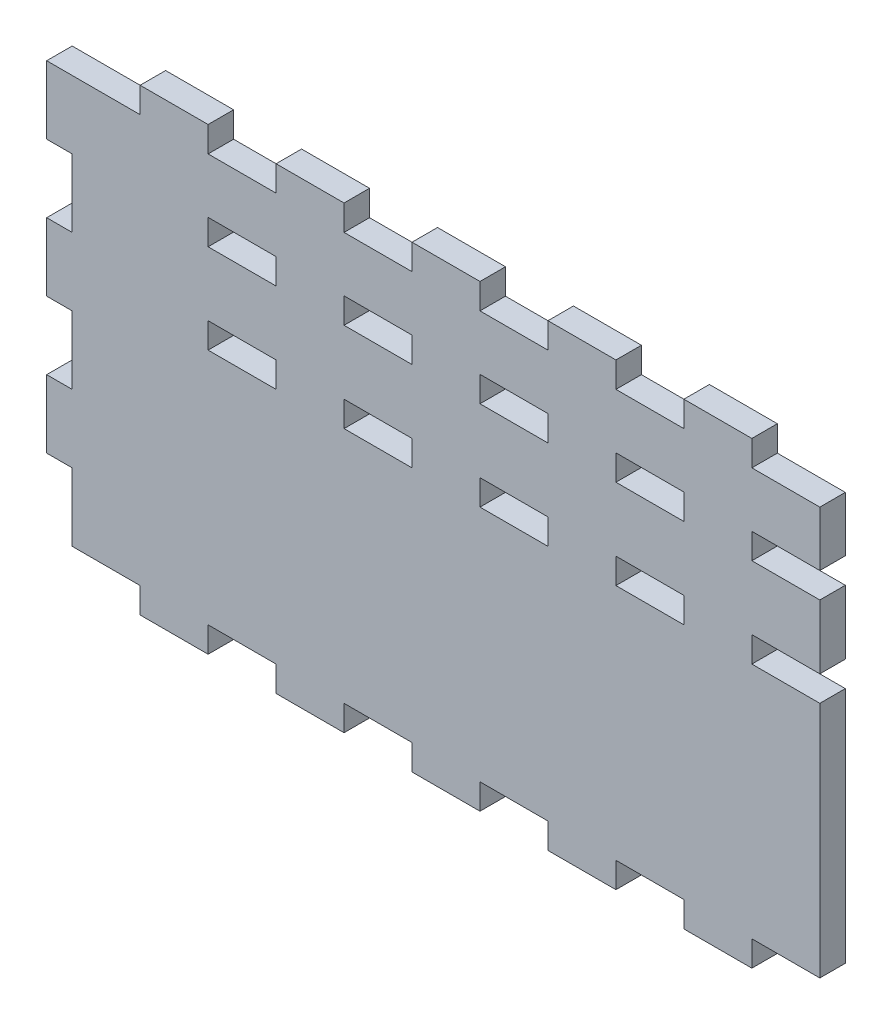
from build123d import *

# Parameters (mm, degrees)
SKETCH1_W               = 279.4
SKETCH1_H               = 152.4
BOSS_EXTRUDE1_DEPTH     = 9.525
SKETCH2_W               = 25.4
SKETCH2_H               = 9.525
BOSS_EXTRUDE2_DEPTH     = 9.525
LPATTERN1_COUNT         = 5
LPATTERN1_PITCH         = 50.8
MIRROR1_COPY_1_SKETCH_W = 25.4
MIRROR1_COPY_1_SKETCH_H = 9.525
MIRROR1_COPY_1_DEPTH    = 9.525
MIRROR1_COPY_2_SKETCH_W = 25.4
MIRROR1_COPY_2_SKETCH_H = 9.525
MIRROR1_COPY_2_DEPTH    = 9.525
MIRROR1_COPY_3_SKETCH_W = 25.4
MIRROR1_COPY_3_SKETCH_H = 9.525
MIRROR1_COPY_3_DEPTH    = 9.525
MIRROR1_COPY_4_SKETCH_W = 25.4
MIRROR1_COPY_4_SKETCH_H = 9.525
MIRROR1_COPY_4_DEPTH    = 9.525
SKETCH3_W               = 9.525
SKETCH3_H               = 25.4
BOSS_EXTRUDE3_DEPTH     = 9.525
LPATTERN2_COUNT         = 3
LPATTERN2_PITCH         = 50.8
SKETCH4_W               = 25.4
SKETCH4_H               = 9.525
CUT_EXTRUDE1_DEPTH      = 10.525
LPATTERN3_COUNT         = 5
LPATTERN3_PITCH         = 50.8
SKETCH5_W               = 25.4
SKETCH5_H               = 9.525
CUT_EXTRUDE2_DEPTH      = 10.525
LPATTERN4_COUNT         = 5
LPATTERN4_PITCH         = 50.8


with BuildPart() as part:
    # Sketch1 → Boss-Extrude1 (new body)
    with BuildSketch(Plane.XY):
        Rectangle(SKETCH1_W, SKETCH1_H)
    extrude(amount=BOSS_EXTRUDE1_DEPTH)

    # Sketch2 → Boss-Extrude2 (add)
    with BuildSketch(Plane.XZ.offset(76.2)):
        with Locations((-101.6, 4.7625)):
            Rectangle(SKETCH2_W, SKETCH2_H)
    boss_extrude2 = extrude(amount=BOSS_EXTRUDE2_DEPTH)

    # LPattern1: Boss-Extrude2 ×5
    with Locations(*[(i * LPATTERN1_PITCH, 0, 0) for i in range(1, LPATTERN1_COUNT)]):
        add(boss_extrude2)

    # Mirror1: Boss-Extrude2 across plane
    add(boss_extrude2.mirror(Plane.ZX))

    # Mirror1 copy 1 sketch → Mirror1 copy 1 (add)
    with BuildSketch(Plane(origin=(50.8, 76.2, 0), x_dir=(1, 0, 0), z_dir=(0, 1, 0))):
        with Locations((-101.6, -4.7625)):
            Rectangle(MIRROR1_COPY_1_SKETCH_W, MIRROR1_COPY_1_SKETCH_H)
    extrude(amount=MIRROR1_COPY_1_DEPTH)

    # Mirror1 copy 2 sketch → Mirror1 copy 2 (add)
    with BuildSketch(Plane(origin=(101.6, 76.2, 0), x_dir=(1, 0, 0), z_dir=(0, 1, 0))):
        with Locations((-101.6, -4.7625)):
            Rectangle(MIRROR1_COPY_2_SKETCH_W, MIRROR1_COPY_2_SKETCH_H)
    extrude(amount=MIRROR1_COPY_2_DEPTH)

    # Mirror1 copy 3 sketch → Mirror1 copy 3 (add)
    with BuildSketch(Plane(origin=(152.4, 76.2, 0), x_dir=(1, 0, 0), z_dir=(0, 1, 0))):
        with Locations((-101.6, -4.7625)):
            Rectangle(MIRROR1_COPY_3_SKETCH_W, MIRROR1_COPY_3_SKETCH_H)
    extrude(amount=MIRROR1_COPY_3_DEPTH)

    # Mirror1 copy 4 sketch → Mirror1 copy 4 (add)
    with BuildSketch(Plane(origin=(203.2, 76.2, 0), x_dir=(1, 0, 0), z_dir=(0, 1, 0))):
        with Locations((-101.6, -4.7625)):
            Rectangle(MIRROR1_COPY_4_SKETCH_W, MIRROR1_COPY_4_SKETCH_H)
    extrude(amount=MIRROR1_COPY_4_DEPTH)

    # Sketch3 → Boss-Extrude3 (add)
    with BuildSketch(Plane.ZY.offset(139.7)):
        with Locations((4.7625, 63.5)):
            Rectangle(SKETCH3_W, SKETCH3_H)
    boss_extrude3 = extrude(amount=BOSS_EXTRUDE3_DEPTH)

    # LPattern2: Boss-Extrude3 ×3
    with Locations(*[(0, -i * LPATTERN2_PITCH, 0) for i in range(1, LPATTERN2_COUNT)]):
        add(boss_extrude3)

    # Sketch4 → Cut-Extrude1 (cut, through all)
    with BuildSketch(Plane(origin=(0, 0, 0), x_dir=(-1, 0, 0), z_dir=(0, 0, -1))):
        with Locations((-127, 17.4625)):
            Rectangle(SKETCH4_W, SKETCH4_H)
    cut_extrude1 = extrude(amount=-CUT_EXTRUDE1_DEPTH, mode=Mode.SUBTRACT)

    # LPattern3: Cut-Extrude1 ×5
    with Locations(*[(-i * LPATTERN3_PITCH, 0, 0) for i in range(1, LPATTERN3_COUNT)]):
        add(cut_extrude1, mode=Mode.SUBTRACT)

    # Sketch5 → Cut-Extrude2 (cut, through all)
    with BuildSketch(Plane.XY.offset(9.525)):
        with Locations((-76.2, 50.905277904)):
            Rectangle(SKETCH5_W, SKETCH5_H)
    cut_extrude2 = extrude(amount=-CUT_EXTRUDE2_DEPTH, mode=Mode.SUBTRACT)

    # LPattern4: Cut-Extrude2 ×5
    with Locations(*[(i * LPATTERN4_PITCH, 0, 0) for i in range(1, LPATTERN4_COUNT)]):
        add(cut_extrude2, mode=Mode.SUBTRACT)


solid = part.part
